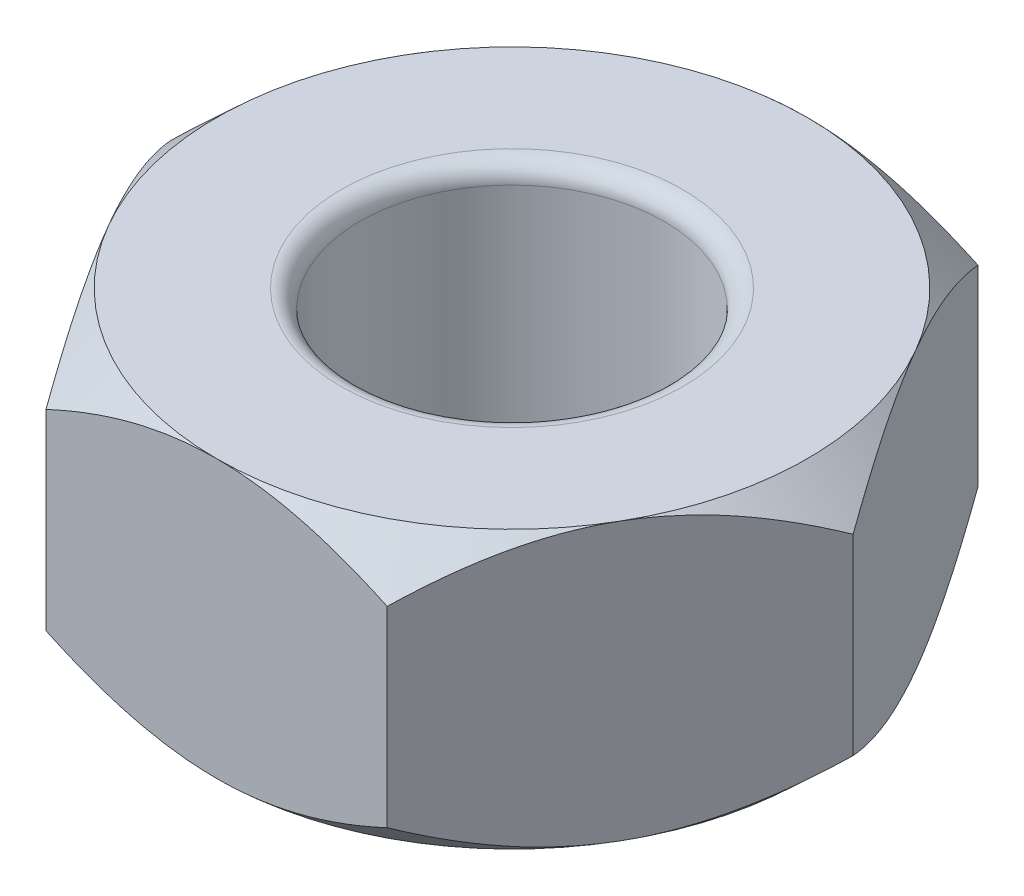
from build123d import *

# Parameters (mm, degrees)
SALIENTE_EXTRUIR1_DEPTH = 15
CROQUIS2_OUTSIDE_W      = 81.348
CROQUIS2_OUTSIDE_H      = 76.398
CROQUIS2_OUTSIDE_R      = 16
CORTAR_EXTRUIR1_DEPTH   = 15
CORTAR_EXTRUIR1_TAPER   = 47
CROQUIS3_OUTSIDE_W      = 81.348
CROQUIS3_OUTSIDE_H      = 76.398
CROQUIS3_OUTSIDE_R      = 16
CORTAR_EXTRUIR2_DEPTH   = 15
CORTAR_EXTRUIR2_TAPER   = 47
CROQUIS4_R              = 8.25
CORTAR_EXTRUIR3_DEPTH   = 15
REDONDEO1_R             = 1


with BuildPart() as part:
    # Croquis1 → Saliente-Extruir1 (new body)
    with BuildSketch(Plane(origin=(0, 0, 0), x_dir=(1, 0, 0), z_dir=(0, 1, 0))):
        Polygon((-9.237604307, -16), (9.237604307, -16), (18.475208614, 0), (9.237604307, 16), (-9.237604307, 16), (-18.475208614, 0), align=None)
    extrude(amount=-SALIENTE_EXTRUIR1_DEPTH)

    # Croquis2 outside → Cortar-Extruir1 (cut)
    with BuildSketch(Plane(origin=(0, 0, 0), x_dir=(1, 0, 0), z_dir=(0, 1, 0))):
        Rectangle(CROQUIS2_OUTSIDE_W, CROQUIS2_OUTSIDE_H)
        Circle(CROQUIS2_OUTSIDE_R, mode=Mode.SUBTRACT)
    extrude(amount=-CORTAR_EXTRUIR1_DEPTH, taper=CORTAR_EXTRUIR1_TAPER, mode=Mode.SUBTRACT)

    # Croquis3 outside → Cortar-Extruir2 (cut)
    with BuildSketch(Plane.XZ.offset(15)):
        Rectangle(CROQUIS3_OUTSIDE_W, CROQUIS3_OUTSIDE_H)
        Circle(CROQUIS3_OUTSIDE_R, mode=Mode.SUBTRACT)
    extrude(amount=-CORTAR_EXTRUIR2_DEPTH, taper=CORTAR_EXTRUIR2_TAPER, mode=Mode.SUBTRACT)

    # Croquis4 → Cortar-Extruir3 (cut)
    with BuildSketch(Plane(origin=(0, 0, 0), x_dir=(1, 0, 0), z_dir=(0, 1, 0))):
        Circle(CROQUIS4_R)
    extrude(amount=-CORTAR_EXTRUIR3_DEPTH, mode=Mode.SUBTRACT)

    # Redondeo1
    redondeo1_edges = [part.edges().sort_by_distance(p)[0] for p in [
        (-8.25, -15, 0),
        (-8.25, 0, 0),
    ]]
    fillet(redondeo1_edges, radius=REDONDEO1_R)


solid = part.part
